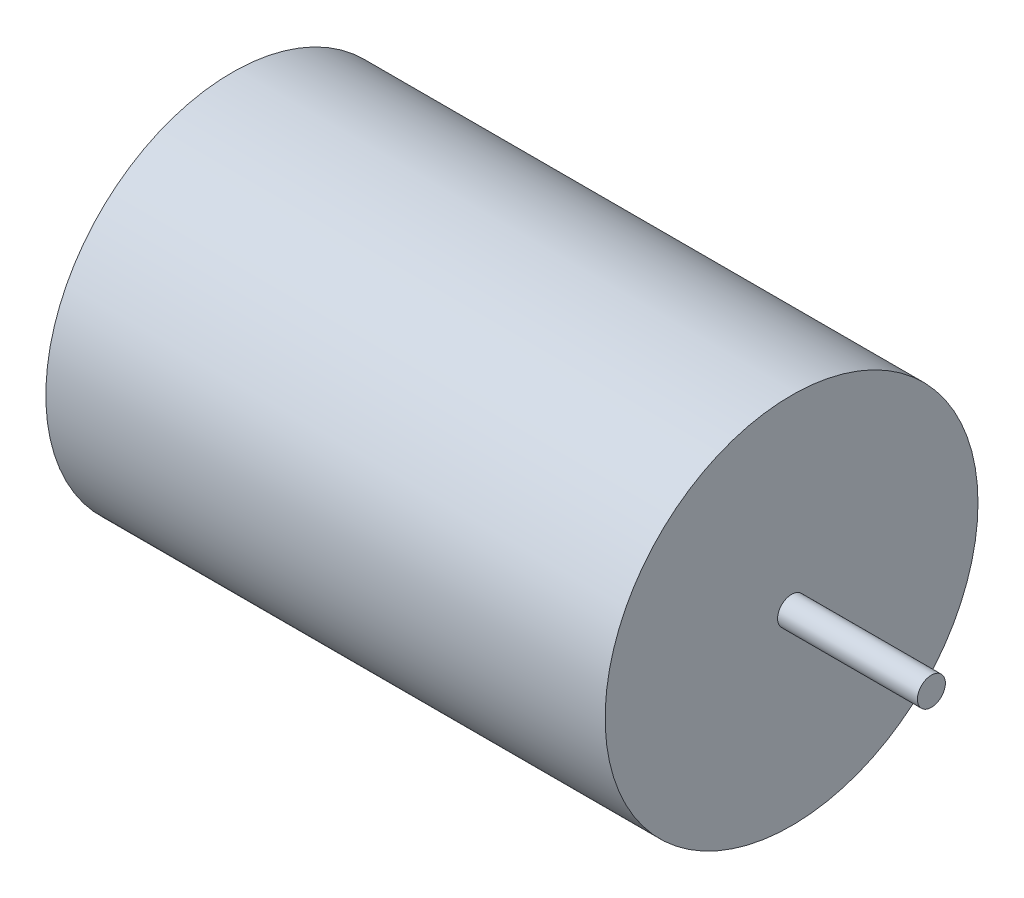
from build123d import *

# Parameters (mm, degrees)
ESQUISSE2_R        = 20
BOSS_EXTRU_1_DEPTH = 60
ESQUISSE3_R        = 1.5
BOSS_EXTRU_2_DEPTH = 15


with BuildPart() as part:
    # Esquisse2 → Boss.-Extru.1 (new body)
    with BuildSketch(Plane(origin=(0, 0, 0), x_dir=(0, 0, -1), z_dir=(1, 0, 0))):
        Circle(ESQUISSE2_R)
    extrude(amount=BOSS_EXTRU_1_DEPTH)

    # Esquisse3 → Boss.-Extru.2 (add)
    with BuildSketch(Plane(origin=(60, 0, 0), x_dir=(0, 0, -1), z_dir=(1, 0, 0))):
        Circle(ESQUISSE3_R)
    extrude(amount=BOSS_EXTRU_2_DEPTH)


solid = part.part
